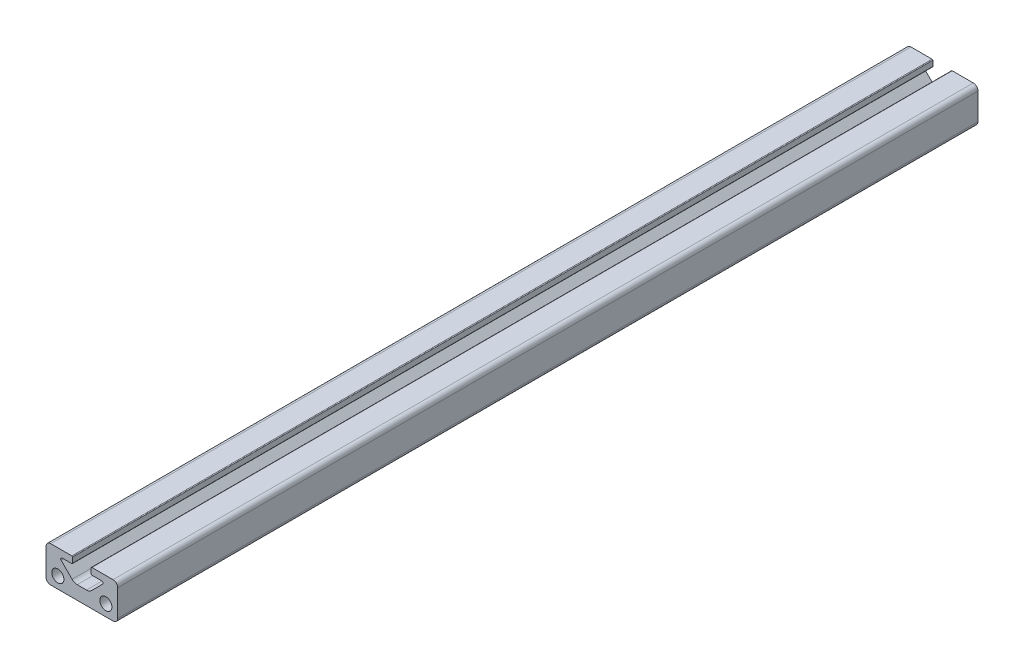
from build123d import *

# Parameters (mm, degrees)
SKETCH3_R           = 2.1463
BOSS_EXTRUDE1_DEPTH = 152.4
FILLET1_R           = 0.254


with BuildPart() as part:
    # Sketch3 → Boss-Extrude1 (new body, symmetric)
    with BuildSketch(Plane.XY):
        with BuildLine():
            Line((-11.049, 12.7), (-3.302, 12.7))
            Line((-3.302, 12.7), (-3.302, 10.328863887))
            Line((-3.302, 10.328863887), (-6.985, 10.328863887))
            ThreePointArc((-6.985, 10.328863887), (-7.454330803, 10.01526707), (-7.344210245, 9.461653642))
            Line((-7.344210245, 9.461653642), (-3.452505379, 5.569948776))
            ThreePointArc((-3.452505379, 5.569948776), (-2.628470073, 5.019345987), (-1.656454155, 4.826))
            Line((-1.656454155, 4.826), (1.656454155, 4.826))
            ThreePointArc((1.656454155, 4.826), (2.628470073, 5.019345987), (3.452505379, 5.569948776))
            Line((3.452505379, 5.569948776), (7.344210245, 9.461653642))
            ThreePointArc((7.344210245, 9.461653642), (7.454330803, 10.01526707), (6.985, 10.328863887))
            Line((6.985, 10.328863887), (3.302, 10.328863887))
            Line((3.302, 10.328863887), (3.302, 12.7))
            Line((3.302, 12.7), (11.049, 12.7))
            ThreePointArc((11.049, 12.7), (12.216433296, 12.216433296), (12.7, 11.049))
            Line((12.7, 11.049), (12.7, 1.651))
            ThreePointArc((12.7, 1.651), (12.216433296, 0.483566704), (11.049, 0))
            Line((11.049, 0), (-11.049, 0))
            ThreePointArc((-11.049, 0), (-12.216433296, 0.483566704), (-12.7, 1.651))
            Line((-12.7, 1.651), (-12.7, 11.049))
            ThreePointArc((-12.7, 11.049), (-12.216433296, 12.216433296), (-11.049, 12.7))
        make_face()
        with Locations((8.509, 4.064)):
            Circle(SKETCH3_R, mode=Mode.SUBTRACT)
        with Locations((-8.509, 4.064)):
            Circle(SKETCH3_R, mode=Mode.SUBTRACT)
    extrude(amount=BOSS_EXTRUDE1_DEPTH, both=True)

    # Fillet1
    fillet1_edges = [part.edges().sort_by_distance(p)[0] for p in [
        (-3.302, 12.7, 0),
        (-3.302, 10.328863887, 0),
        (3.302, 10.328863887, 0),
        (3.302, 12.7, 0),
    ]]
    fillet(fillet1_edges, radius=FILLET1_R)


solid = part.part
